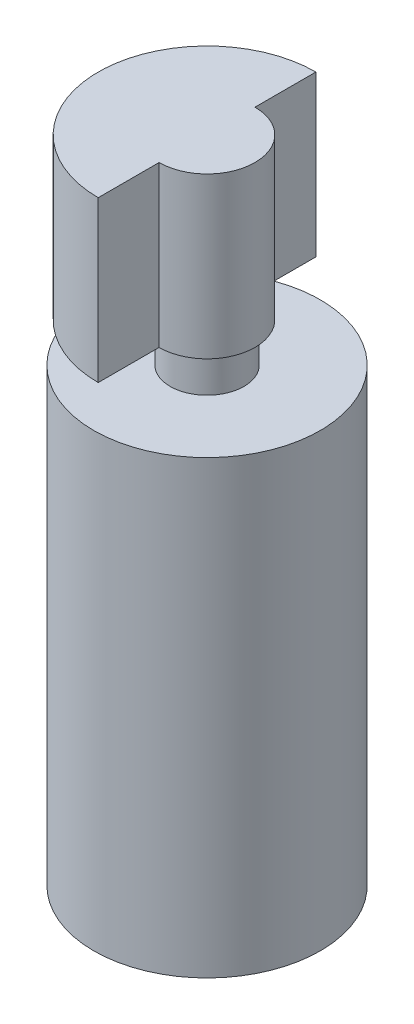
from build123d import *

# Parameters (mm, degrees)
SKETCH1_R           = 3
BOSS_EXTRUDE1_DEPTH = 11.938
SKETCH2_R           = 0.9779
BOSS_EXTRUDE2_DEPTH = 5.2832
BOSS_EXTRUDE3_DEPTH = 4.2418


with BuildPart() as part:
    # Sketch1 → Boss-Extrude1 (new body)
    with BuildSketch(Plane(origin=(0, 0, 0), x_dir=(1, 0, 0), z_dir=(0, 1, 0))):
        Circle(SKETCH1_R)
    extrude(amount=BOSS_EXTRUDE1_DEPTH)

    # Sketch2 → Boss-Extrude2 (add)
    with BuildSketch(Plane(origin=(0, 11.938, 0), x_dir=(1, 0, 0), z_dir=(0, 1, 0))):
        Circle(SKETCH2_R)
    extrude(amount=BOSS_EXTRUDE2_DEPTH)

    # Sketch4 → Boss-Extrude3 (add)
    with BuildSketch(Plane(origin=(0, 17.2212, -17.2212), x_dir=(1, 0, 0), z_dir=(0, -1, 0))):
        with BuildLine():
            Line((0, 20.1041), (0, 18.4912))
            ThreePointArc((0, 18.4912), (1.27, 17.2212), (0, 15.9512))
            Line((0, 15.9512), (0, 14.3383))
            ThreePointArc((0, 14.3383), (-2.8829, 17.2212), (0, 20.1041))
        make_face()
    extrude(amount=BOSS_EXTRUDE3_DEPTH)


solid = part.part
